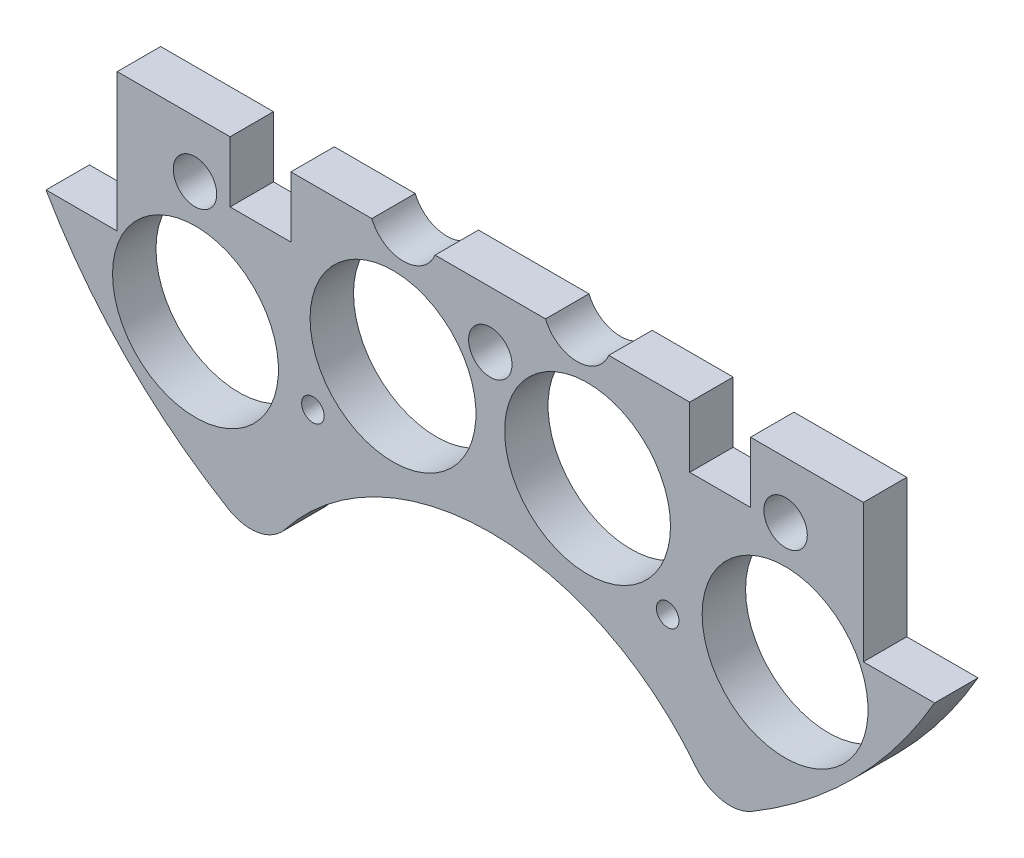
from build123d import *

# Parameters (mm, degrees)
SKETCH1_R                 = 1.651
BOSS_EXTRUDE2_DEPTH       = 6.35
SKETCH2_R                 = 1.143
CUT_EXTRUDE1_DEPTH        = 7.35
SKETCH3_R                 = 12.1285
CUT_EXTRUDE2_DEPTH        = 7.35
SKETCH4_W                 = 28.562713242
SKETCH4_H                 = 11.677503754
BOSS_EXTRUDE3_DEPTH       = 6.35
SKETCH5_W                 = 216.7214489
SKETCH5_H                 = 130.569220634
CUT_EXTRUDE4_DEPTH        = 7.35
SKETCH6_R                 = 38.1
CUT_EXTRUDE5_DEPTH        = 60.96
FILLET1_R                 = 6.35
FILLET2_R                 = 6.35
SKETCH102_W               = 8.89
SKETCH102_H               = 8.89
CUT_EXTRUDE101_DEPTH      = 7.3500001
SKETCH105_R               = 5
CUT_EXTRUDE104_DEPTH      = 10
SKETCH106_R               = 3.175
CUT_EXTRUDE105_DEPTH      = 103.378
CUT_EXTRUDE105_DEPTH_BACK = 1
SKETCH158_R               = 1.651
CUT_EXTRUDE157_DEPTH      = 97.79


with BuildPart() as part:
    # Sketch1 → Boss-Extrude2 (new body)
    with BuildSketch(Plane.XY):
        with BuildLine():
            Line((-64.964441474, 37.338), (-54.550441474, 37.338))
            Line((-54.550441474, 37.338), (-54.550441474, -37.338))
            Line((-54.550441474, -37.338), (-64.964441474, -37.338))
            ThreePointArc((-64.964441474, -37.338), (0, -74.93), (64.964441474, -37.338))
            Line((64.964441474, -37.338), (54.550441474, -37.338))
            Line((54.550441474, -37.338), (54.550441474, 37.338))
            Line((54.550441474, 37.338), (64.964441474, 37.338))
            ThreePointArc((64.964441474, 37.338), (0, 74.93), (-64.964441474, 37.338))
        make_face()
        with Locations((-46.482, 11.049)):
            Circle(SKETCH1_R, mode=Mode.SUBTRACT)
        with Locations((-21.083270032, 10.795)):
            Circle(SKETCH1_R, mode=Mode.SUBTRACT)
        with Locations((-21.083270032, -10.795)):
            Circle(SKETCH1_R, mode=Mode.SUBTRACT)
        with Locations((-46.482, -11.049)):
            Circle(SKETCH1_R, mode=Mode.SUBTRACT)
        with Locations((46.482, -11.049)):
            Circle(SKETCH1_R, mode=Mode.SUBTRACT)
        with Locations((21.083270032, -10.795)):
            Circle(SKETCH1_R, mode=Mode.SUBTRACT)
        with Locations((21.083270032, 10.795)):
            Circle(SKETCH1_R, mode=Mode.SUBTRACT)
        with Locations((46.482, 11.049)):
            Circle(SKETCH1_R, mode=Mode.SUBTRACT)
    extrude(amount=BOSS_EXTRUDE2_DEPTH)

    # Sketch2 → Cut-Extrude1 (cut, through all)
    with BuildSketch(Plane.XY.offset(6.35)):
        with Locations((-6.731, 62.23)):
            Circle(SKETCH2_R)
        with Locations((6.731, 62.23)):
            Circle(SKETCH2_R)
    extrude(amount=-CUT_EXTRUDE1_DEPTH, mode=Mode.SUBTRACT)

    # Sketch3 → Cut-Extrude2 (cut, through all)
    with BuildSketch(Plane(origin=(0, 0, 0), x_dir=(-1, 0, 0), z_dir=(0, 0, -1))):
        with Locations((-43.105229381, -43.105229381)):
            Circle(SKETCH3_R)
        with Locations((14.224, -34.29)):
            Circle(SKETCH3_R)
        with Locations((14.224, 34.29)):
            Circle(SKETCH3_R)
        with Locations((-43.105229381, 43.105229381)):
            Circle(SKETCH3_R)
        with Locations((43.105229381, 43.105229381)):
            Circle(SKETCH3_R)
        with Locations((-14.224, 34.29)):
            Circle(SKETCH3_R)
        with Locations((-14.224, -34.29)):
            Circle(SKETCH3_R)
        with Locations((43.105229381, -43.105229381)):
            Circle(SKETCH3_R)
    extrude(amount=-CUT_EXTRUDE2_DEPTH, mode=Mode.SUBTRACT)

    # Sketch4 → Boss-Extrude3 (add)
    with BuildSketch(Plane(origin=(0, 0, 0), x_dir=(-1, 0, 0), z_dir=(0, 0, -1))):
        with Locations((-1.488809975, 62.152540216)):
            Rectangle(SKETCH4_W, SKETCH4_H)
    extrude(amount=-BOSS_EXTRUDE3_DEPTH)

    # Sketch5 → Cut-Extrude4 (cut, through all)
    with BuildSketch(Plane(origin=(0, 0, 0), x_dir=(-1, 0, 0), z_dir=(0, 0, -1))):
        with Locations((23.316688373, 48.139610317)):
            Rectangle(SKETCH5_W, SKETCH5_H)
    extrude(amount=-CUT_EXTRUDE4_DEPTH, mode=Mode.SUBTRACT)

    # Sketch6 → Cut-Extrude5 (cut)
    with BuildSketch(Plane(origin=(0, 0, 0), x_dir=(-1, 0, 0), z_dir=(0, 0, -1))):
        with Locations((0, -86.312058398)):
            Circle(SKETCH6_R)
    extrude(amount=-CUT_EXTRUDE5_DEPTH, mode=Mode.SUBTRACT)

    # Fillet1
    fillet1_edges = [part.edges().sort_by_distance(p)[0] for p in [
        (-33.000960548, -67.271401821, 3.175),
    ]]
    fillet(fillet1_edges, radius=FILLET1_R)

    # Fillet2
    fillet2_edges = [part.edges().sort_by_distance(p)[0] for p in [
        (33.000960548, -67.271401821, 3.175),
    ]]
    fillet(fillet2_edges, radius=FILLET2_R)

    # Sketch102 → Cut-Extrude101 (cut, through all)
    with BuildSketch(Plane(origin=(0, 0, 0), x_dir=(-1, 0, 0), z_dir=(0, 0, -1))):
        with Locations((-33.605441474, -21.59)):
            Rectangle(SKETCH102_W, SKETCH102_H)
        with Locations((33.605441474, -21.59)):
            Rectangle(SKETCH102_W, SKETCH102_H)
    extrude(amount=-CUT_EXTRUDE101_DEPTH, mode=Mode.SUBTRACT)

    # Sketch105 → Cut-Extrude104 (cut)
    with BuildSketch(Plane(origin=(0, 0, 0), x_dir=(-1, 0, 0), z_dir=(0, 0, -1))):
        with Locations((-12.7, -15.24)):
            Circle(SKETCH105_R)
        with Locations((12.7, -15.24)):
            Circle(SKETCH105_R)
    extrude(amount=-CUT_EXTRUDE104_DEPTH, mode=Mode.SUBTRACT)

    # Sketch106 → Cut-Extrude105 (cut, two sides)
    with BuildSketch(Plane(origin=(30.092005081, 4.08352975, 25.4), x_dir=(-1, 0, 0), z_dir=(0, 0, -1))) as cut_extrude105_sk:
        with Locations((73.272005081, -29.48352975)):
            Circle(SKETCH106_R)
        with Locations((30.092005081, -29.48352975)):
            Circle(SKETCH106_R)
        with Locations((-13.087994919, -29.48352975)):
            Circle(SKETCH106_R)
    extrude(amount=CUT_EXTRUDE105_DEPTH, mode=Mode.SUBTRACT)
    extrude(cut_extrude105_sk.sketch, amount=-CUT_EXTRUDE105_DEPTH_BACK, mode=Mode.SUBTRACT)

    # Sketch158 → Cut-Extrude157 (cut)
    with BuildSketch(Plane(origin=(30.092005081, 4.08352975, -22.225), x_dir=(-1, 0, 0), z_dir=(0, 0, -1))):
        with Locations((4.154396091, -49.728759131)):
            Circle(SKETCH158_R)
        with Locations((56.02961407, -49.728759131)):
            Circle(SKETCH158_R)
    extrude(amount=-CUT_EXTRUDE157_DEPTH, mode=Mode.SUBTRACT)


solid = part.part
